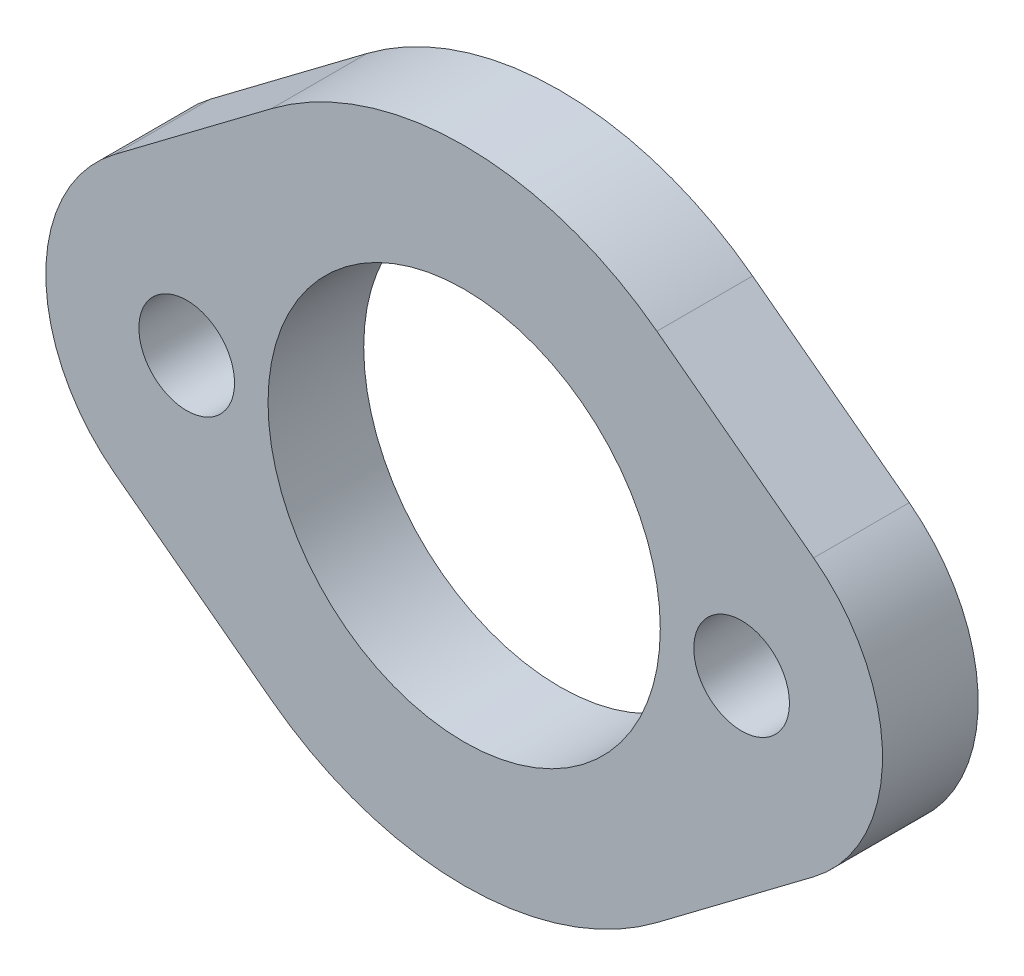
from build123d import *

# Parameters (mm, degrees)
SKETCH1_R           = 2.5
SKETCH1_R_2         = 10.25
BOSS_EXTRUDE1_DEPTH = 5


with BuildPart() as part:
    # Sketch1 → Boss-Extrude1 (new body)
    with BuildSketch(Plane.XY):
        with BuildLine():
            Line((-18.262940366, -7.217732658), (-10.073546599, -13.382307683))
            ThreePointArc((-10.073546599, -13.382307683), (0, -16.75), (10.073546599, -13.382307683))
            Line((10.073546599, -13.382307683), (18.262940366, -7.217732658))
            ThreePointArc((18.262940366, -7.217732658), (21.863878029, 0), (18.262940366, 7.217732658))
            Line((18.262940366, 7.217732658), (10.073546599, 13.382307683))
            ThreePointArc((10.073546599, 13.382307683), (0, 16.75), (-10.073546599, 13.382307683))
            Line((-10.073546599, 13.382307683), (-18.262940366, 7.217732658))
            ThreePointArc((-18.262940366, 7.217732658), (-21.863878029, 0), (-18.262940366, -7.217732658))
        make_face()
        with Locations((14.5, 0)):
            Circle(SKETCH1_R, mode=Mode.SUBTRACT)
        with Locations((-14.5, 0)):
            Circle(SKETCH1_R, mode=Mode.SUBTRACT)
        Circle(SKETCH1_R_2, mode=Mode.SUBTRACT)
    extrude(amount=BOSS_EXTRUDE1_DEPTH)


solid = part.part
